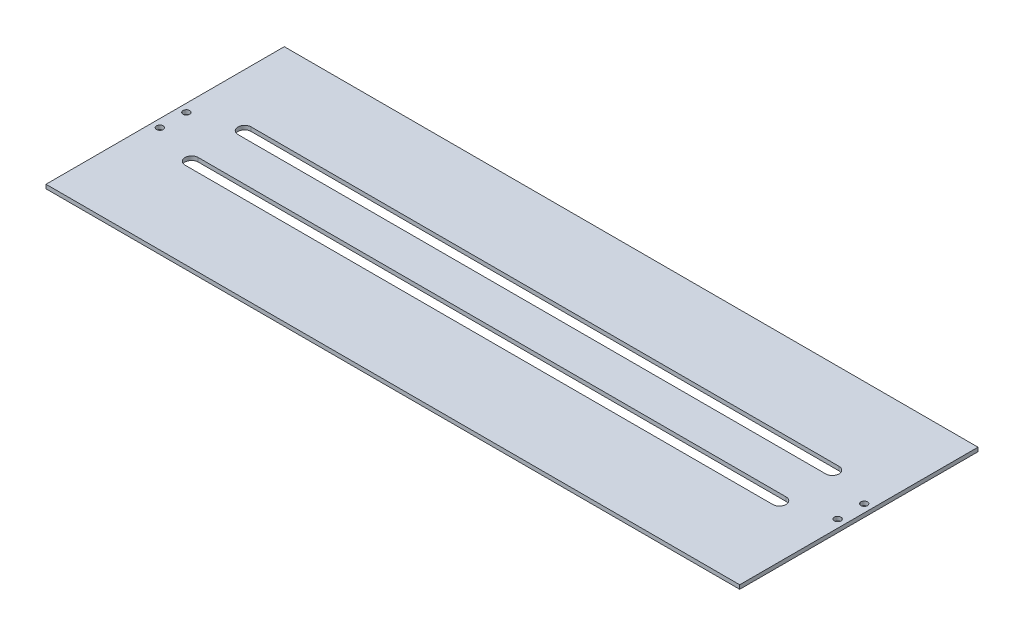
from build123d import *

# Parameters (mm, degrees)
SKETCH1_W                  = 524
SKETCH1_H                  = 180
BOSS_EXTRUDE1_DEPTH        = 3
SKETCH2_W                  = 444
SKETCH2_H                  = 10
TRACKS_DEPTH               = 4
SKETCH3_R                  = 2.5
SCREW_MOUNTING_HOLES_DEPTH = 4


with BuildPart() as part:
    # Sketch1 → Boss-Extrude1 (new body)
    with BuildSketch(Plane(origin=(0, 0, 0), x_dir=(1, 0, 0), z_dir=(0, 1, 0))):
        with Locations((262, 90)):
            Rectangle(SKETCH1_W, SKETCH1_H)
    extrude(amount=BOSS_EXTRUDE1_DEPTH)

    # Sketch2 → Tracks (cut, through all)
    with BuildSketch(Plane.XZ):
        with BuildLine():
            ThreePointArc((484, -65), (489, -70), (484, -75))
            Line((484, -75), (484, -65))
        make_face()
        with Locations((262, -70)):
            Rectangle(SKETCH2_W, SKETCH2_H)
        with BuildLine():
            ThreePointArc((40, -75), (35, -70), (40, -65))
            Line((40, -65), (40, -75))
        make_face()
    tracks = extrude(amount=-TRACKS_DEPTH, mode=Mode.SUBTRACT)

    # Sketch3 → screw mounting holes (cut, through all)
    with BuildSketch(Plane.XZ):
        with Locations((6, -80)):
            Circle(SKETCH3_R)
        with Locations((518, -80)):
            Circle(SKETCH3_R)
    screw_mounting_holes = extrude(amount=-SCREW_MOUNTING_HOLES_DEPTH, mode=Mode.SUBTRACT)

    # Mirror2: Tracks, screw mounting holes across plane
    add(tracks.mirror(Plane(origin=(0, 0, -90), x_dir=(1, 0, 0), z_dir=(0, 0, -1))), mode=Mode.SUBTRACT)
    add(screw_mounting_holes.mirror(Plane(origin=(0, 0, -90), x_dir=(1, 0, 0), z_dir=(0, 0, -1))), mode=Mode.SUBTRACT)


solid = part.part
